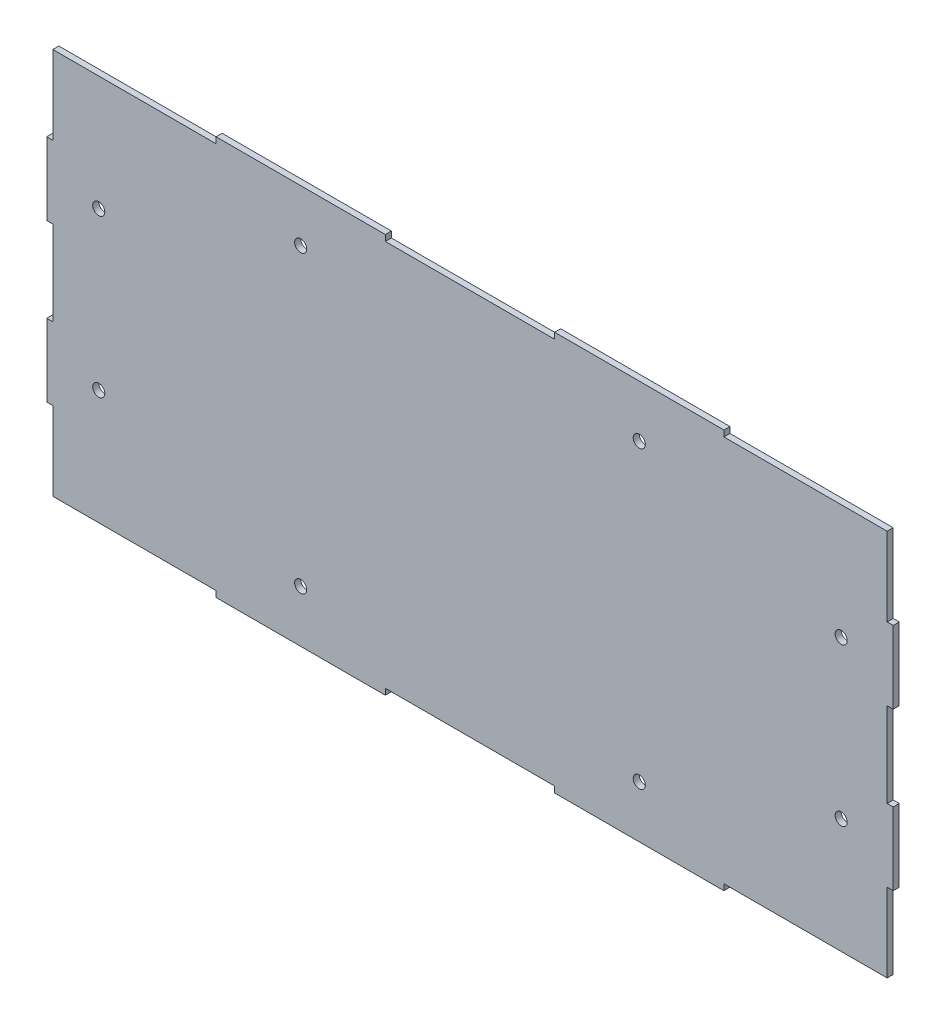
from build123d import *

# Parameters (mm, degrees)
SKETCH1_R           = 2.5
BOSS_EXTRUDE1_DEPTH = 2.5


with BuildPart() as part:
    # Sketch1 → Boss-Extrude1 (new body)
    with BuildSketch(Plane.XY):
        Polygon((-172.5, 80), (-105, 80), (-105, 82.5), (-35, 82.5), (-35, 80), (35, 80), (35, 82.5), (105, 82.5), (105, 80), (172.5, 80), (172.5, 47.5), (175, 47.5), (175, 17.5), (172.5, 17.5), (172.5, -17.5), (175, -17.5), (175, -47.5), (172.5, -47.5), (172.5, -80), (105, -80), (105, -82.5), (35, -82.5), (35, -80), (-35, -80), (-35, -82.5), (-105, -82.5), (-105, -80), (-172.5, -80), (-172.5, -47.5), (-175, -47.5), (-175, -17.5), (-172.5, -17.5), (-172.5, 17.5), (-175, 17.5), (-175, 47.5), (-172.5, 47.5), align=None)
        with Locations((-70, -61)):
            Circle(SKETCH1_R, mode=Mode.SUBTRACT)
        with Locations((70, -61)):
            Circle(SKETCH1_R, mode=Mode.SUBTRACT)
        with Locations((70, 61)):
            Circle(SKETCH1_R, mode=Mode.SUBTRACT)
        with Locations((-70, 61)):
            Circle(SKETCH1_R, mode=Mode.SUBTRACT)
        with Locations((153.5, 32.5)):
            Circle(SKETCH1_R, mode=Mode.SUBTRACT)
        with Locations((153.5, -32.5)):
            Circle(SKETCH1_R, mode=Mode.SUBTRACT)
        with Locations((-153.5, -32.5)):
            Circle(SKETCH1_R, mode=Mode.SUBTRACT)
        with Locations((-153.5, 32.5)):
            Circle(SKETCH1_R, mode=Mode.SUBTRACT)
    extrude(amount=BOSS_EXTRUDE1_DEPTH)


solid = part.part
